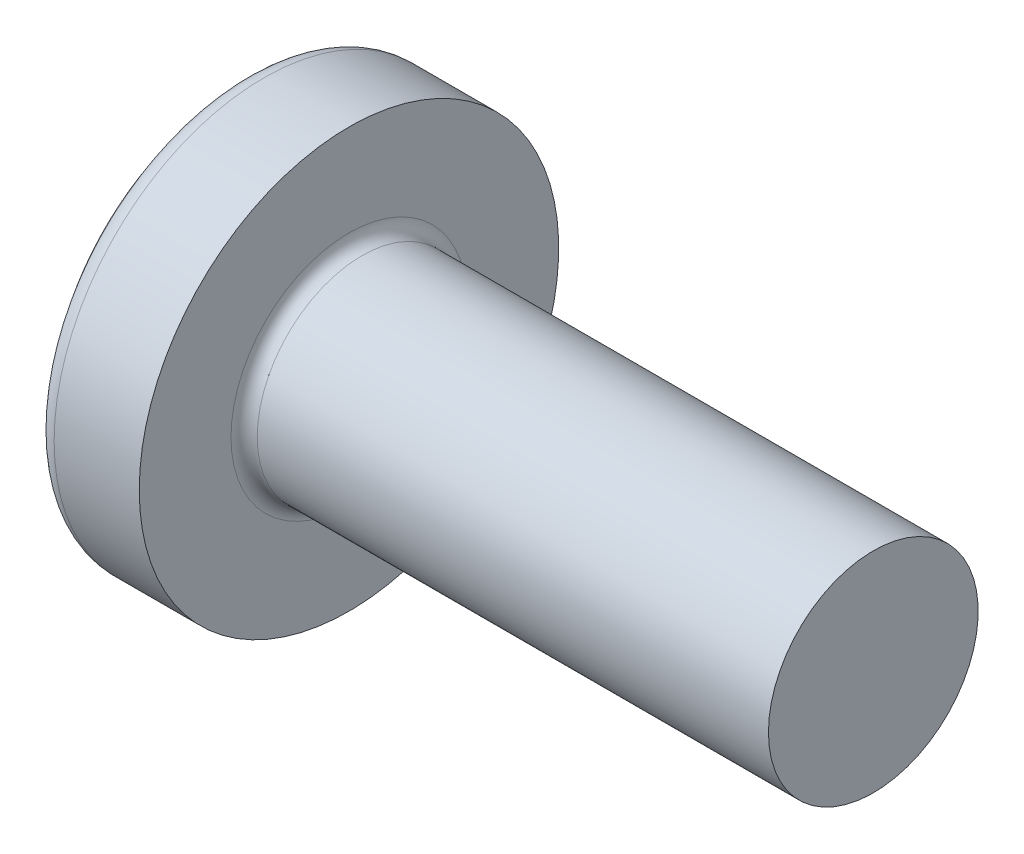
from build123d import *

# Parameters (mm, degrees)
FILLET1_R    = 0.1
SKETCH3_W    = 0.48
SKETCH3_H    = 1.6
SKETCH4_W    = 0.48
SKETCH4_H    = 0.702553256
RECPAT_COUNT = 2
RECPAT_ANGLE = 90


with BuildPart() as part:
    # BodySke → Base-Revolve (revolve)
    with BuildSketch(Plane.XY):
        with BuildLine():
            Line((1.3, 0.8), (1.3, 1.6))
            Line((1.3, 1.6), (0.650675799, 1.6))
            ThreePointArc((0.650675799, 1.6), (0.585036553, 1.584875829), (0.532633829, 1.542553191))
            ThreePointArc((0.532633829, 1.542553191), (0.136907172, 0.815960959), (0, 0))
            Line((0, 0), (5.3, 0))
            Line((5.3, 0), (5.3, 0.8))
            Line((5.3, 0.8), (1.3, 0.8))
        make_face()
    revolve(axis=Axis((-25.4, 0, 0), (1, 0, 0)))

    # Fillet1
    fillet1_edges = [part.edges().sort_by_distance(p)[0] for p in [
        (1.3, -0.8, 0),
    ]]
    fillet(fillet1_edges, radius=FILLET1_R)

    # Sketch3 → Recess section 0
    with BuildSketch(Plane(origin=(0, 0, 0), x_dir=(0, 0, -1), z_dir=(1, 0, 0))):
        Rectangle(SKETCH3_W, SKETCH3_H)
    # Sketch4 → Recess section 1
    with BuildSketch(Plane(origin=(0.9, 0, 0), x_dir=(0, 0, -1), z_dir=(1, 0, 0))):
        Rectangle(SKETCH4_W, SKETCH4_H)
    recess = loft(mode=Mode.SUBTRACT)

    # RecPat: Recess ×2 about axis
    recpat_axis = Axis((0, 0, 0), (1, 0, 0))
    for i in range(1, RECPAT_COUNT):
        add(recess.rotate(recpat_axis, i * RECPAT_ANGLE / (RECPAT_COUNT - 1)), mode=Mode.SUBTRACT)

    # RecCorSke → RecessCore (revolve, cut)
    with BuildSketch(Plane.XY):
        Polygon((0, 0), (0, 0.418434131), (0.9, 0.3555), (1.015508952, 0), align=None)
    revolve(axis=Axis((-3.175, 0, 0), (1, 0, 0)), mode=Mode.SUBTRACT)


solid = part.part
